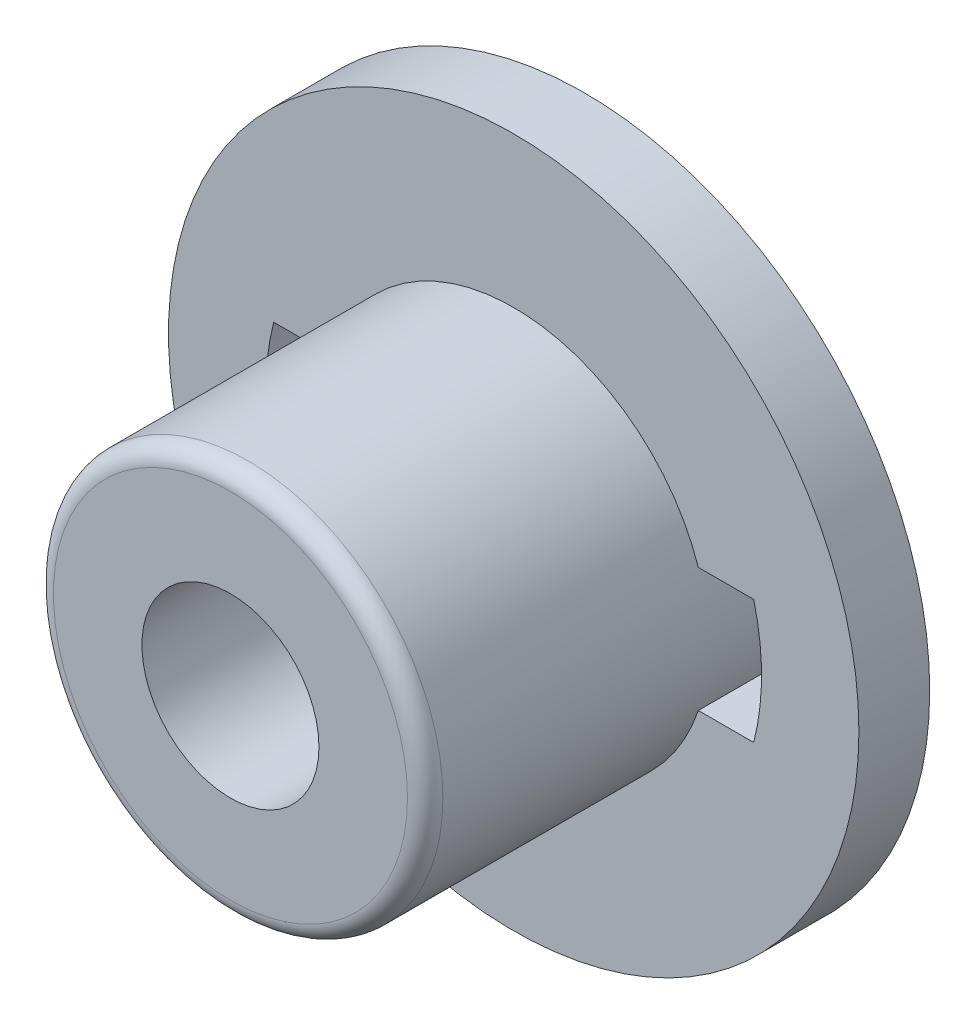
from build123d import *

# Parameters (mm, degrees)
SKETCH_1_R          = 3.9
SKETCH_1_R_2        = 2.2
SKETCH_1_R_3        = 1
EXTRUDE_1_DEPTH     = 0.8
SKETCH_1_4_R        = 2.2
SKETCH_1_4_R_2      = 1
EXTRUDE_2_DEPTH     = 3.2
FILLET_1_R          = 0.2
SKETCH_2_R          = 1.15
CUT_EXTRUDE_1_DEPTH = 0.5
CUT_EXTRUDE_2_REACH = 8.813


with BuildPart() as part:
    # Sketch 1 → Extrude 1 (new body)
    with BuildSketch(Plane.XY):
        Circle(SKETCH_1_R)
        Circle(SKETCH_1_R_2, mode=Mode.SUBTRACT)
        Circle(SKETCH_1_R_2)
        Circle(SKETCH_1_R_3, mode=Mode.SUBTRACT)
    extrude(amount=-EXTRUDE_1_DEPTH)

    # Sketch 1_4 → Extrude 2 (add)
    with BuildSketch(Plane.XY):
        Circle(SKETCH_1_4_R)
        Circle(SKETCH_1_4_R_2, mode=Mode.SUBTRACT)
    extrude(amount=EXTRUDE_2_DEPTH)

    # Fillet 1
    fillet_1_edges = [part.edges().sort_by_distance(p)[0] for p in [
        (-2.2, 0, 3.2),
    ]]
    fillet(fillet_1_edges, radius=FILLET_1_R)

    # Sketch 2 → Cut-Extrude 1 (cut)
    with BuildSketch(Plane(origin=(0, 0, -0.8), x_dir=(-1, 0, 0), z_dir=(0, 0, -1))):
        Circle(SKETCH_2_R)
    extrude(amount=-CUT_EXTRUDE_1_DEPTH, mode=Mode.SUBTRACT)

    # Sketch 3 → Cut-Extrude 2 (cut, up to next)
    with BuildSketch(Plane(origin=(0, 0, -0.8), x_dir=(-1, 0, 0), z_dir=(0, 0, -1)), mode=Mode.PRIVATE) as cut_extrude_2_sk1:
        with BuildLine():
            ThreePointArc((-2.711088342, 0.7), (-2.8, 0), (-2.711088342, -0.7))
            Line((-2.711088342, -0.7), (-2.085665361, -0.7))
            ThreePointArc((-2.085665361, -0.7), (-2.2, 0), (-2.085665361, 0.7))
            Line((-2.085665361, 0.7), (-2.711088342, 0.7))
        make_face()
    cut_extrude_2_tool1 = extrude(cut_extrude_2_sk1.sketch, amount=-CUT_EXTRUDE_2_REACH, mode=Mode.PRIVATE) & part.part
    # Sketch 3 → Cut-Extrude 2 (cut, up to next)
    with BuildSketch(Plane(origin=(0, 0, -0.8), x_dir=(-1, 0, 0), z_dir=(0, 0, -1)), mode=Mode.PRIVATE) as cut_extrude_2_sk2:
        with BuildLine():
            Line((2.085665361, -0.7), (2.711088342, -0.7))
            ThreePointArc((2.711088342, -0.7), (2.77768315, -0.352812019), (2.8, 0))
            ThreePointArc((2.8, 0), (2.77768315, 0.352812019), (2.711088342, 0.7))
            Line((2.711088342, 0.7), (2.085665361, 0.7))
            ThreePointArc((2.085665361, 0.7), (2.1712282, 0.354637988), (2.2, 0))
            ThreePointArc((2.2, 0), (2.1712282, -0.354637988), (2.085665361, -0.7))
        make_face()
    cut_extrude_2_tool2 = extrude(cut_extrude_2_sk2.sketch, amount=-CUT_EXTRUDE_2_REACH, mode=Mode.PRIVATE) & part.part
    # Sketch 3 → Cut-Extrude 2 (cut, up to next)
    with BuildSketch(Plane(origin=(0, 0, -0.8), x_dir=(-1, 0, 0), z_dir=(0, 0, -1)), mode=Mode.PRIVATE) as cut_extrude_2_sk3:
        with BuildLine():
            ThreePointArc((-2.711088342, 0.7), (-2.8, 0), (-2.711088342, -0.7))
            Line((-2.711088342, -0.7), (-2.085665361, -0.7))
            ThreePointArc((-2.085665361, -0.7), (-2.2, 0), (-2.085665361, 0.7))
            Line((-2.085665361, 0.7), (-2.711088342, 0.7))
        make_face()
    cut_extrude_2_tool3 = extrude(cut_extrude_2_sk3.sketch, amount=-CUT_EXTRUDE_2_REACH, mode=Mode.PRIVATE) & part.part
    # Sketch 3 → Cut-Extrude 2 (cut, up to next)
    with BuildSketch(Plane(origin=(0, 0, -0.8), x_dir=(-1, 0, 0), z_dir=(0, 0, -1)), mode=Mode.PRIVATE) as cut_extrude_2_sk4:
        with BuildLine():
            Line((2.085665361, -0.7), (2.711088342, -0.7))
            ThreePointArc((2.711088342, -0.7), (2.77768315, -0.352812019), (2.8, 0))
            ThreePointArc((2.8, 0), (2.77768315, 0.352812019), (2.711088342, 0.7))
            Line((2.711088342, 0.7), (2.085665361, 0.7))
            ThreePointArc((2.085665361, 0.7), (2.1712282, 0.354637988), (2.2, 0))
            ThreePointArc((2.2, 0), (2.1712282, -0.354637988), (2.085665361, -0.7))
        make_face()
    cut_extrude_2_tool4 = extrude(cut_extrude_2_sk4.sketch, amount=-CUT_EXTRUDE_2_REACH, mode=Mode.PRIVATE) & part.part
    add(cut_extrude_2_tool1.solids().sort_by_distance((2.466051, 0, -0.8))[0], mode=Mode.SUBTRACT)
    add(cut_extrude_2_tool2.solids().sort_by_distance((-2.466051, 0, -0.8))[0], mode=Mode.SUBTRACT)
    add(cut_extrude_2_tool3.solids().sort_by_distance((2.466051, 0, -0.8))[0], mode=Mode.SUBTRACT)
    add(cut_extrude_2_tool4.solids().sort_by_distance((-2.466051, 0, -0.8))[0], mode=Mode.SUBTRACT)


solid = part.part
